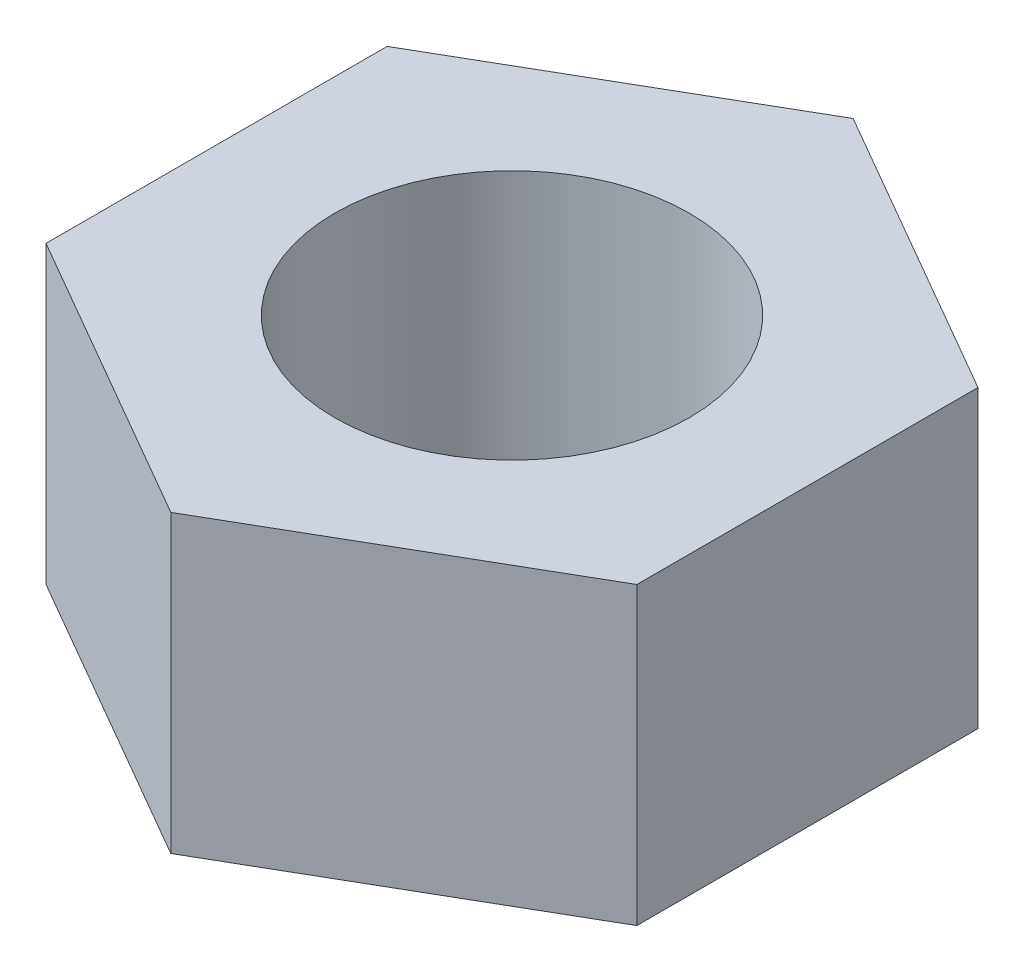
from build123d import *

# Parameters (mm, degrees)
ESQUISSE1_R        = 3
BOSS_EXTRU_1_DEPTH = 5


with BuildPart() as part:
    # Esquisse1 → Boss.-Extru.1 (new body)
    with BuildSketch(Plane(origin=(0, 0, 0), x_dir=(1, 0, 0), z_dir=(0, 1, 0))):
        Polygon((-5, 2.886751346), (0, 5.773502692), (5, 2.886751346), (5, -2.886751346), (0, -5.773502692), (-5, -2.886751346), align=None)
        Circle(ESQUISSE1_R, mode=Mode.SUBTRACT)
    extrude(amount=BOSS_EXTRU_1_DEPTH)


solid = part.part
